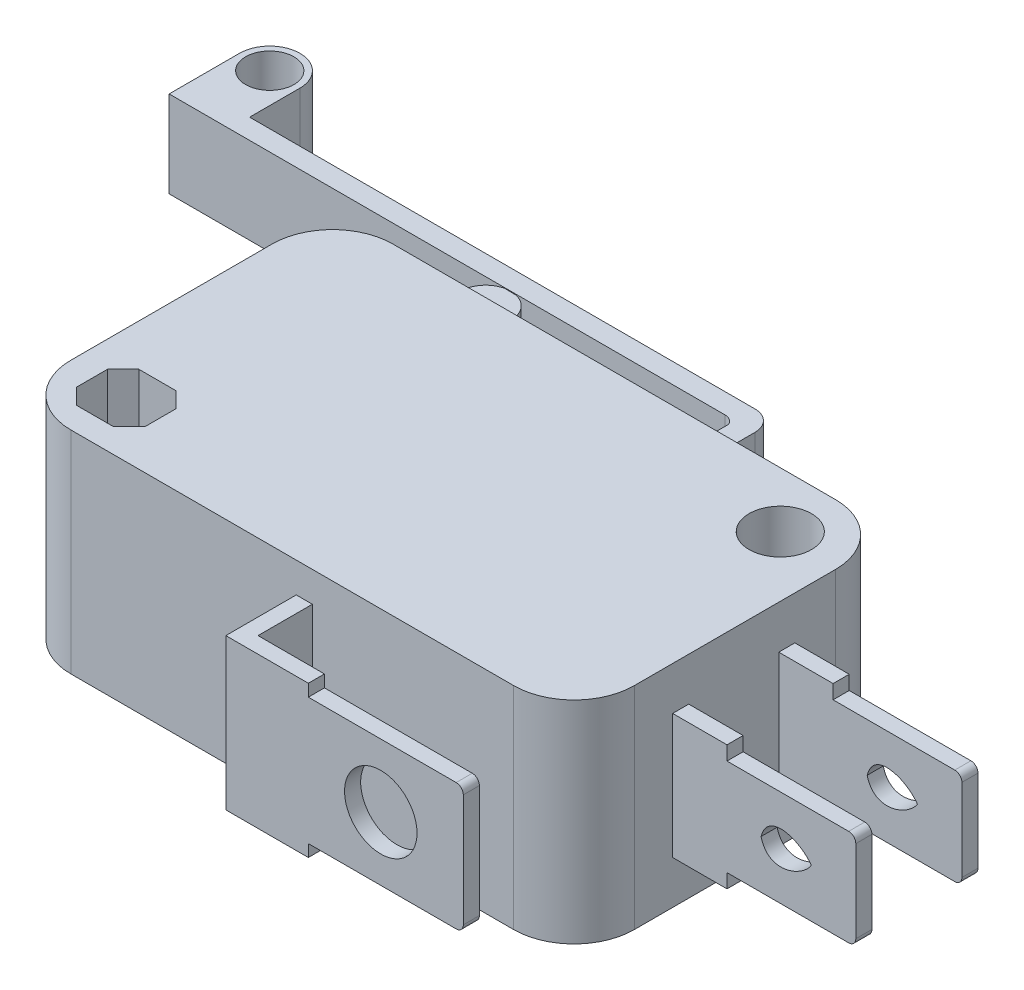
from build123d import *

# Parameters (mm, degrees)
CROQUIS1_R              = 1.55
SALIENTE_EXTRUIR1_DEPTH = 10.5
CROQUIS2_R              = 1.2
SALIENTE_EXTRUIR2_DEPTH = 4.3
SALIENTE_EXTRUIR6_DEPTH = 4.3
SALIENTE_EXTRUIR7_DEPTH = 7.5
CROQUIS5_R              = 1.8
CORTAR_EXTRUIR1_DEPTH   = 1.5
CROQUIS6_W              = 9.1
CROQUIS6_H              = 0.8
SALIENTE_EXTRUIR8_DEPTH = 6.2
CORTAR_EXTRUIR2_DEPTH   = 7.2


with BuildPart() as part:
    # Croquis1 → Saliente-Extruir1 (new body)
    with BuildSketch(Plane(origin=(0, 0, 0), x_dir=(1, 0, 0), z_dir=(0, 1, 0))):
        with BuildLine():
            Line((3, 0), (25, 0))
            ThreePointArc((25, 0), (27.121320344, 0.878679656), (28, 3))
            Line((28, 3), (28, 13))
            ThreePointArc((28, 13), (27.121320344, 15.121320344), (25, 16))
            Line((25, 16), (3, 16))
            ThreePointArc((3, 16), (0.878679656, 15.121320344), (0, 13))
            Line((0, 13), (0, 3))
            ThreePointArc((0, 3), (0.878679656, 0.878679656), (3, 0))
        make_face()
        with Locations((25, 13.25)):
            Circle(CROQUIS1_R, mode=Mode.SUBTRACT)
        Polygon((1.3, 3.525), (2.075, 4.3), (3.925, 4.3), (4.7, 3.525), (4.7, 1.975), (3.925, 1.2), (2.075, 1.2), (1.3, 1.975), (1.3, 2.75), align=None, mode=Mode.SUBTRACT)
    extrude(amount=SALIENTE_EXTRUIR1_DEPTH)

    # Croquis2 → Saliente-Extruir2 (add)
    with BuildSketch(Plane(origin=(0, 3.1, 0), x_dir=(1, 0, 0), z_dir=(0, 1, 0))):
        with BuildLine():
            Line((-12.117246013, 20), (15.502753987, 20))
            ThreePointArc((15.502753987, 20), (15.795636527, 19.916267232), (16, 19.69037582))
            Line((16, 19.69037582), (16, 16))
            Line((16, 16), (17, 16))
            Line((17, 16), (17, 20))
            ThreePointArc((17, 20), (16.707106781, 20.707106781), (16, 21))
            Line((16, 21), (-9.117246013, 21))
            Line((-9.117246013, 21), (-9.117246013, 23.5))
            ThreePointArc((-9.117246013, 23.5), (-10.617246013, 25), (-12.117246013, 23.5))
            Line((-12.117246013, 23.5), (-12.117246013, 21))
            Line((-12.117246013, 21), (-12.117246013, 20))
        make_face()
        with Locations((-10.617246013, 23.5)):
            Circle(CROQUIS2_R, mode=Mode.SUBTRACT)
    extrude(amount=SALIENTE_EXTRUIR2_DEPTH)

    # Croquis3 → Saliente-Extruir6 (add)
    with BuildSketch(Plane(origin=(0, 3.1, 0), x_dir=(1, 0, 0), z_dir=(0, 1, 0))):
        with BuildLine():
            Line((4.579945188, 19.96820969), (5.178103837, 19.958862719))
            ThreePointArc((5.178103837, 19.958862719), (5.85002436, 19.513199542), (6.110061503, 18.75))
            Line((6.110061503, 18.75), (6.110061503, 16))
            Line((6.110061503, 16), (3.610061503, 16))
            Line((3.610061503, 16), (3.610061503, 18.75))
            ThreePointArc((3.610061503, 18.75), (3.882143972, 19.52857389), (4.579945188, 19.96820969))
        make_face()
    extrude(amount=SALIENTE_EXTRUIR6_DEPTH)

    # Croquis4 → Saliente-Extruir7 (add)
    with BuildSketch(Plane(origin=(0, 1.5, 0), x_dir=(1, 0, 0), z_dir=(0, 1, 0))):
        Polygon((15, 0), (15, -2.7), (26, -2.7), (26, -3.5), (15, -3.5), (14.2, -3.5), (14.2, 0), align=None)
    extrude(amount=SALIENTE_EXTRUIR7_DEPTH)

    # Croquis5 → Cortar-Extruir1 (cut)
    with BuildSketch(Plane.XY.offset(3.5)):
        with Locations((21.9, 5.25)):
            Circle(CROQUIS5_R)
        with BuildLine():
            Line((26, 1.5), (18.3, 1.5))
            Line((18.3, 1.5), (18.3, 2.1))
            Line((18.3, 2.1), (25.646446609, 2.1))
            ThreePointArc((25.646446609, 2.1), (25.896446609, 2.203553391), (26, 2.453553391))
            Line((26, 2.453553391), (26, 8.046446609))
            ThreePointArc((26, 8.046446609), (25.896446609, 8.296446609), (25.646446609, 8.4))
            Line((25.646446609, 8.4), (18.3, 8.4))
            Line((18.3, 8.4), (18.3, 9))
            Line((18.3, 9), (27.293222539, 9))
            Line((27.293222539, 9), (27.293222539, 1.5))
            Line((27.293222539, 1.5), (26, 1.5))
        make_face()
    extrude(amount=-CORTAR_EXTRUIR1_DEPTH, mode=Mode.SUBTRACT)

    # Croquis6 → Saliente-Extruir8 (add)
    with BuildSketch(Plane(origin=(0, 2.15, 0), x_dir=(1, 0, 0), z_dir=(0, 1, 0))):
        with Locations((32.55, 10.574019752)):
            Rectangle(CROQUIS6_W, CROQUIS6_H)
        with Locations((32.55, 5.301623485)):
            Rectangle(CROQUIS6_W, CROQUIS6_H)
    extrude(amount=SALIENTE_EXTRUIR8_DEPTH)

    # Croquis7 → Cortar-Extruir2 (cut)
    with BuildSketch(Plane(origin=(0, 0, -10.974019752), x_dir=(-1, 0, 0), z_dir=(0, 0, -1))):
        with BuildLine():
            Line((-37.1, 2.15), (-30.7, 2.15))
            Line((-30.7, 2.15), (-30.7, 2.85))
            Line((-30.7, 2.85), (-36.746446609, 2.85))
            ThreePointArc((-36.746446609, 2.85), (-36.996446609, 2.953553391), (-37.1, 3.203553391))
            Line((-37.1, 3.203553391), (-37.1, 7.296446609))
            ThreePointArc((-37.1, 7.296446609), (-36.996446609, 7.546446609), (-36.746446609, 7.65))
            Line((-36.746446609, 7.65), (-30.7, 7.65))
            Line((-30.7, 7.65), (-30.7, 8.35))
            Line((-30.7, 8.35), (-37.1, 8.35))
            Line((-37.1, 8.35), (-38.596530357, 8.35))
            Line((-38.596530357, 8.35), (-38.596530357, 2.85))
            Line((-38.596530357, 2.85), (-38.596530357, 2.15))
            Line((-38.596530357, 2.15), (-37.1, 2.15))
        make_face()
        with BuildLine():
            add(Edge.make_bspline(
                [(-32.392984362, 5.25), (-32.743324346, 3.873805387), (-34.382207103, 4.479328863), (-34.892984362, 5.25)],
                knots=[0, 0, 0, 0, 1, 1, 1, 1], degree=3))
            add(Edge.make_bspline(
                [(-32.392984362, 5.25), (-32.743324346, 6.626194613), (-34.382207103, 6.020671137), (-34.892984362, 5.25)],
                knots=[0, 0, 0, 0, 1, 1, 1, 1], degree=3))
        make_face()
    extrude(amount=-CORTAR_EXTRUIR2_DEPTH, mode=Mode.SUBTRACT)


solid = part.part
